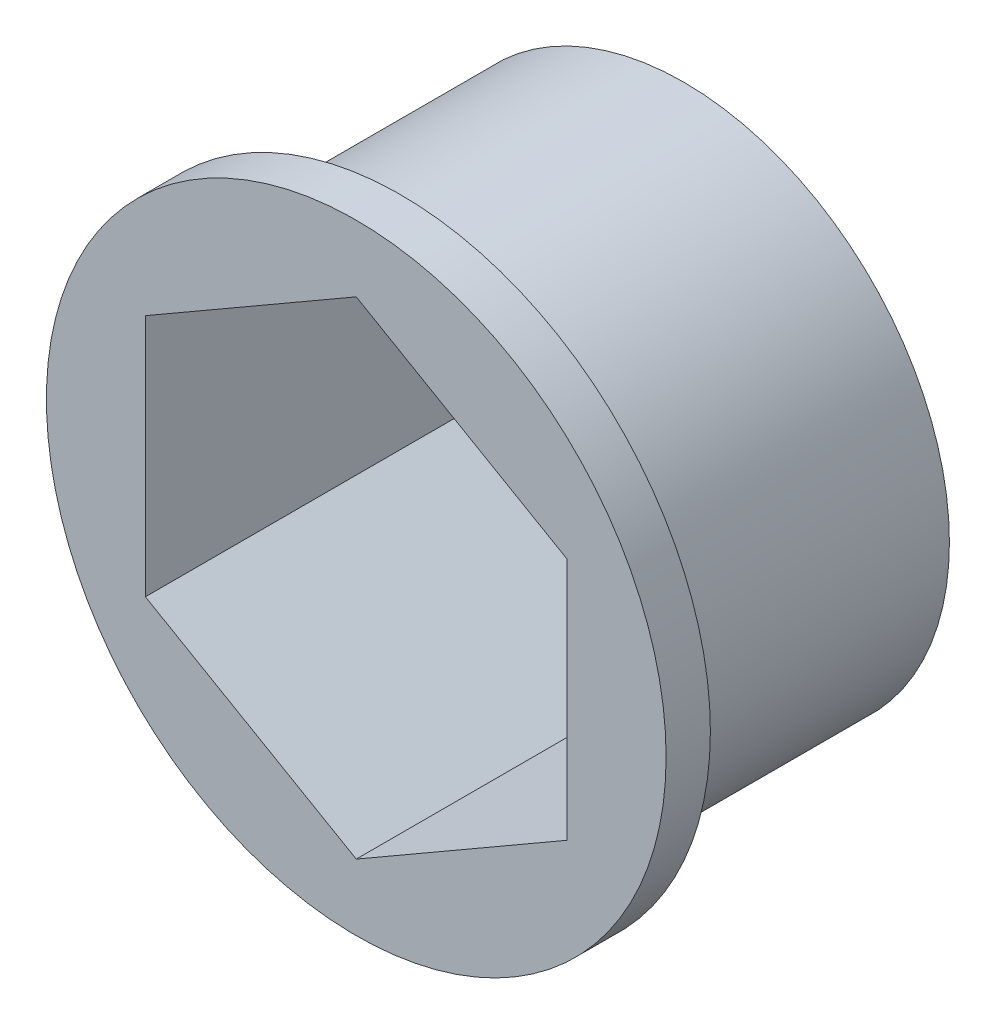
from build123d import *

# Parameters (mm, degrees)
SKETCH1_R               = 12
SKETCH1_R_2             = 6.4
BOSS_EXTRUDE1_DEPTH     = 7.4
SKETCH3_R               = 14
BOSS_EXTRUDE3_DEPTH     = 2
CUT_EXTRUDE4_DEPTH      = 22.136697945
CUT_EXTRUDE4_DEPTH_BACK = 22.136697945


with BuildPart() as part:
    # Sketch1 → Boss-Extrude1 (new, symmetric)
    with BuildSketch(Plane.XY):
        Circle(SKETCH1_R)
        Circle(SKETCH1_R_2, mode=Mode.SUBTRACT)
    extrude(amount=BOSS_EXTRUDE1_DEPTH, both=True)

    # Sketch3 → Boss-Extrude3 (add)
    with BuildSketch(Plane.XY.offset(7.4)):
        Circle(SKETCH3_R)
    extrude(amount=-BOSS_EXTRUDE3_DEPTH)

    # Sketch1_4 → Cut-Extrude4 (cut, two sides: drawn at the far end of the back side and taken through both)
    with BuildSketch(Plane.XY.offset(-CUT_EXTRUDE4_DEPTH_BACK)):
        Polygon((-9.526279442, -5.5), (0, -11), (9.526279442, -5.5), (9.526279442, 5.5), (0, 11), (-9.526279442, 5.5), align=None)
    extrude(amount=CUT_EXTRUDE4_DEPTH + CUT_EXTRUDE4_DEPTH_BACK, mode=Mode.SUBTRACT)


solid = part.part
